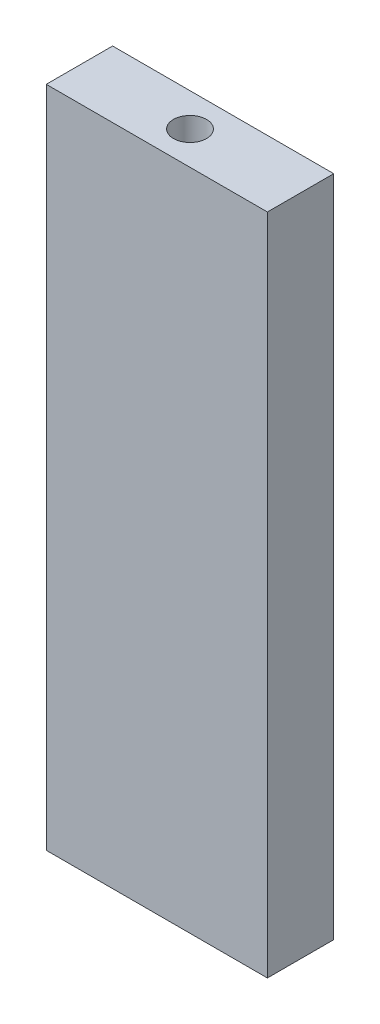
from build123d import *

# Parameters (mm, degrees)
SKETCH1_W           = 20
SKETCH1_H           = 60
BOSS_EXTRUDE1_DEPTH = 6
SKETCH2_R           = 1.5
CUT_EXTRUDE1_DEPTH  = 10


with BuildPart() as part:
    # Sketch1 → Boss-Extrude1 (new body)
    with BuildSketch(Plane.XY):
        Rectangle(SKETCH1_W, SKETCH1_H)
    extrude(amount=BOSS_EXTRUDE1_DEPTH)

    # Sketch2 → Cut-Extrude1 (cut)
    with BuildSketch(Plane(origin=(0, 30, 0), x_dir=(1, 0, 0), z_dir=(0, 1, 0))):
        with Locations((0, -3)):
            Circle(SKETCH2_R)
    cut_extrude1 = extrude(amount=-CUT_EXTRUDE1_DEPTH, mode=Mode.SUBTRACT)

    # Mirror1: Cut-Extrude1 across plane
    add(cut_extrude1.mirror(Plane.ZX), mode=Mode.SUBTRACT)


solid = part.part
